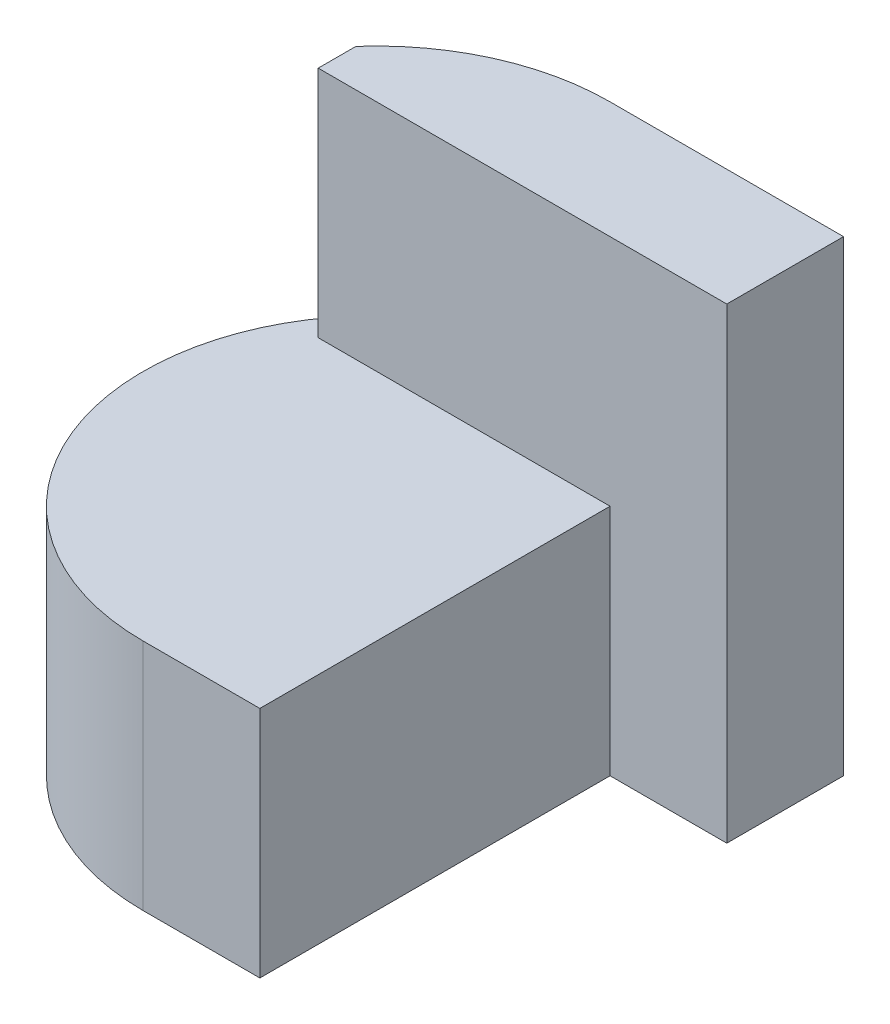
from build123d import *

# Parameters (mm, degrees)
SKETCH1_W           = 40
SKETCH1_H           = 40
BOSS_EXTRUDE1_DEPTH = 40
SKETCH2_W           = 5
SKETCH2_H           = 20
CUT_EXTRUDE1_DEPTH  = 40
CUT_EXTRUDE2_DEPTH  = 40
SKETCH4_W           = 10
SKETCH4_H           = 30
CUT_EXTRUDE3_DEPTH  = 40
SKETCH5_W           = 30
SKETCH5_H           = 20
CUT_EXTRUDE4_DEPTH  = 40


with BuildPart() as part:
    # Sketch1 → Boss-Extrude1 (new body)
    with BuildSketch(Plane.XY):
        with Locations((20, 20)):
            Rectangle(SKETCH1_W, SKETCH1_H)
    extrude(amount=BOSS_EXTRUDE1_DEPTH)

    # Sketch2 → Cut-Extrude1 (cut)
    with BuildSketch(Plane.XY.offset(40)):
        with Locations((2.5, 30)):
            Rectangle(SKETCH2_W, SKETCH2_H)
    extrude(amount=-CUT_EXTRUDE1_DEPTH, mode=Mode.SUBTRACT)

    # Sketch3 → Cut-Extrude2 (cut)
    with BuildSketch(Plane(origin=(0, 0, 0), x_dir=(1, 0, 0), z_dir=(0, 1, 0))):
        with BuildLine():
            ThreePointArc((0, -20.000000105), (5.857864339, -5.857864414), (20, 0))
            Line((20, 0), (0, 0))
            Line((0, 0), (0, -20.000000105))
        make_face()
        with BuildLine():
            ThreePointArc((20, -40), (5.857864414, -34.142135661), (0, -20.000000105))
            Line((0, -20.000000105), (0, -40))
            Line((0, -40), (20, -40))
        make_face()
    extrude(amount=CUT_EXTRUDE2_DEPTH, mode=Mode.SUBTRACT)

    # Sketch4 → Cut-Extrude3 (cut)
    with BuildSketch(Plane(origin=(0, 40, 0), x_dir=(1, 0, 0), z_dir=(0, 1, 0))):
        with Locations((35, -25)):
            Rectangle(SKETCH4_W, SKETCH4_H)
    extrude(amount=-CUT_EXTRUDE3_DEPTH, mode=Mode.SUBTRACT)

    # Sketch5 → Cut-Extrude4 (cut)
    with BuildSketch(Plane(origin=(30, 0, 0), x_dir=(0, 0, -1), z_dir=(1, 0, 0))):
        with Locations((-25, 30)):
            Rectangle(SKETCH5_W, SKETCH5_H)
    extrude(amount=-CUT_EXTRUDE4_DEPTH, mode=Mode.SUBTRACT)


solid = part.part
